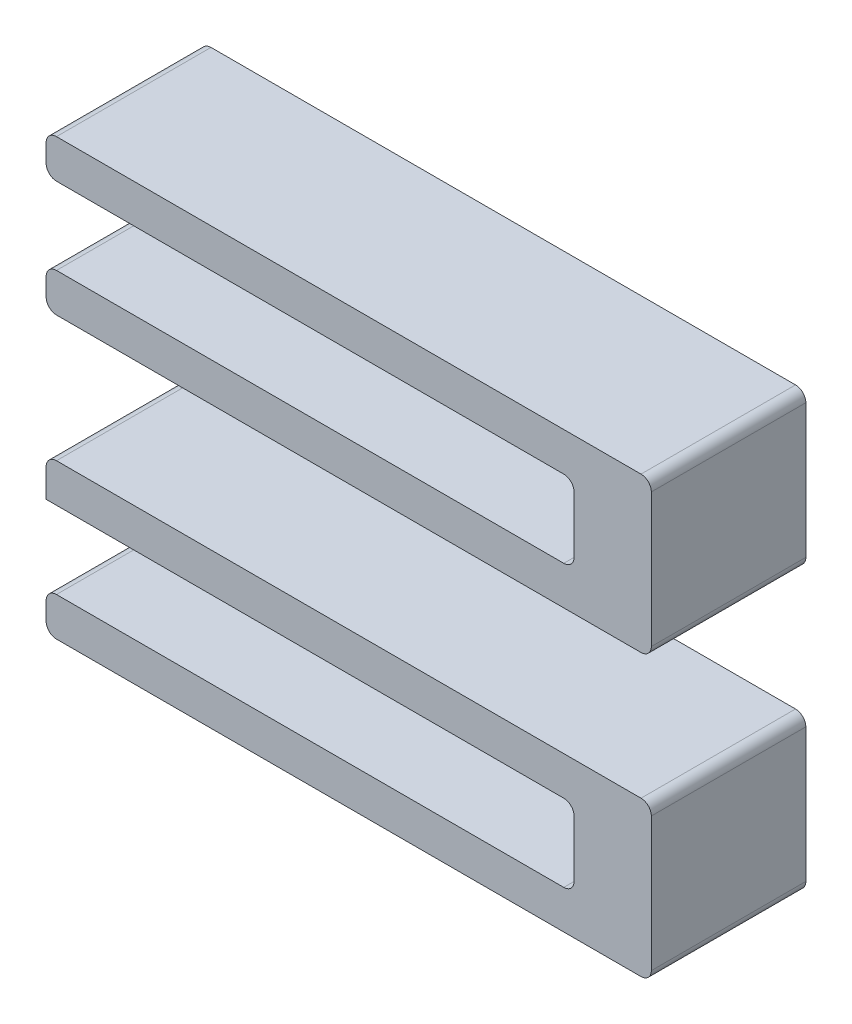
from build123d import *

# Parameters (mm, degrees)
BOSS_EXTRUDE1_DEPTH   = 6
BOSS_EXTRUDE1_2_DEPTH = 6
SKETCH2_4_W           = 20.5
SKETCH2_4_H           = 0.7
BOSS_EXTRUDE3_DEPTH   = 1.2
FILLET2_R             = 0.4
FILLET3_R             = 0.4


with BuildPart() as part:
    # Sketch2 → Boss-Extrude1 (new body)
    with BuildSketch(Plane.XY):
        Polygon((0, 1.5), (0, 0), (23.5, 0), (23.5, 6), (0, 6), (0, 4.5), (20.5, 4.5), (20.5, 1.5), align=None)
    extrude(amount=BOSS_EXTRUDE1_DEPTH)



with BuildPart() as body_2:
    # Sketch2 → Boss-Extrude1 2 (new body)
    with BuildSketch(Plane.XY):
        Polygon((20.5, -6.399471306), (20.5, -9.399471306), (0, -9.399471306), (0, -10.899471306), (23.5, -10.899471306), (23.5, -4.899471306), (0, -4.899471306), (0, -6.399471306), align=None)
    extrude(amount=BOSS_EXTRUDE1_2_DEPTH)


with BuildPart() as part_1:
    add(part.part)

    add(body_2.part)  # Boss-Extrude3 merges body 2
    # Sketch2_4 → Boss-Extrude3 (add)
    with BuildSketch(Plane.XY):
        with Locations((10.25, 4.15)):
            Rectangle(SKETCH2_4_W, SKETCH2_4_H)
        with Locations((10.25, -9.049471306)):
            Rectangle(SKETCH2_4_W, SKETCH2_4_H)
    extrude(amount=BOSS_EXTRUDE3_DEPTH)

    # Fillet2
    fillet2_edges = [part_1.edges().sort_by_distance(p)[0] for p in [
        (0, 4.5, 3.6),
        (20.5, 1.5, 3),
        (20.5, 3.8, 0.6),
        (20.5, 4.5, 3.6),
        (23.5, 6, 3),
        (23.5, 0, 3),
        (0, 0, 3),
        (0, 1.5, 3),
        (0, 3.8, 0.6),
        (0, 6, 3),
    ]]
    fillet(fillet2_edges, radius=FILLET2_R)

    # Fillet3
    fillet3_edges = [part_1.edges().sort_by_distance(p)[0] for p in [
        (23.5, -10.899471306, 3),
        (23.5, -4.899471306, 3),
        (20.5, -6.399471306, 3),
        (20.5, -9.399471306, 3.6),
        (20.5, -8.699471306, 0.6),
        (0, -10.899471306, 3),
        (0, -9.399471306, 3.6),
        (0, -8.699471306, 0.6),
        (0, -4.899471306, 3),
    ]]
    fillet(fillet3_edges, radius=FILLET3_R)


solid = part_1.part
